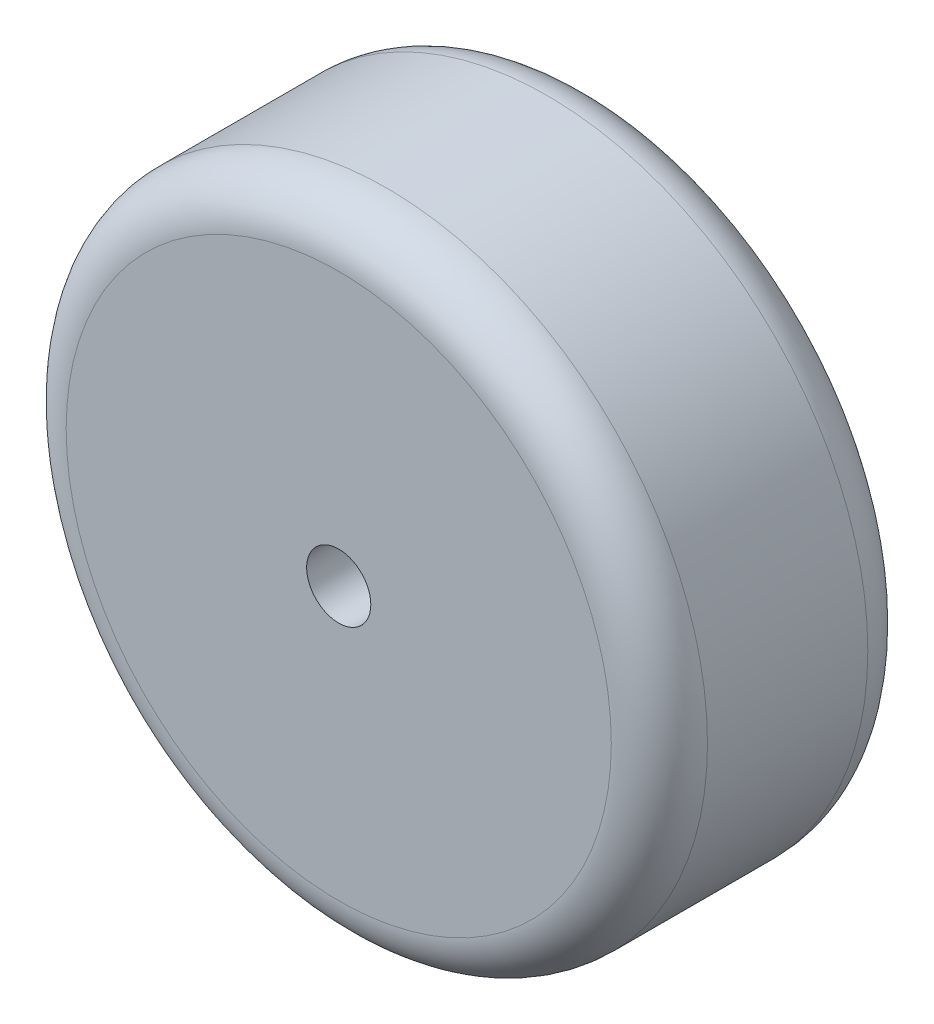
from build123d import *

# Parameters (mm, degrees)
CROQUIS1_R              = 10
SALIENTE_EXTRUIR1_DEPTH = 8
REDONDEO1_R             = 1.5
CROQUIS3_R              = 1
CORTAR_EXTRUIR1_DEPTH   = 9


with BuildPart() as part:
    # Croquis1 → Saliente-Extruir1 (new body)
    with BuildSketch(Plane.XY):
        Circle(CROQUIS1_R)
    extrude(amount=SALIENTE_EXTRUIR1_DEPTH)

    # Redondeo1
    redondeo1_edges = [part.edges().sort_by_distance(p)[0] for p in [
        (-10, 0, 0),
        (-10, 0, 8),
    ]]
    fillet(redondeo1_edges, radius=REDONDEO1_R)

    # Croquis3 → Cortar-Extruir1 (cut, through all)
    with BuildSketch(Plane.XY.offset(8)):
        Circle(CROQUIS3_R)
    extrude(amount=-CORTAR_EXTRUIR1_DEPTH, mode=Mode.SUBTRACT)


solid = part.part
